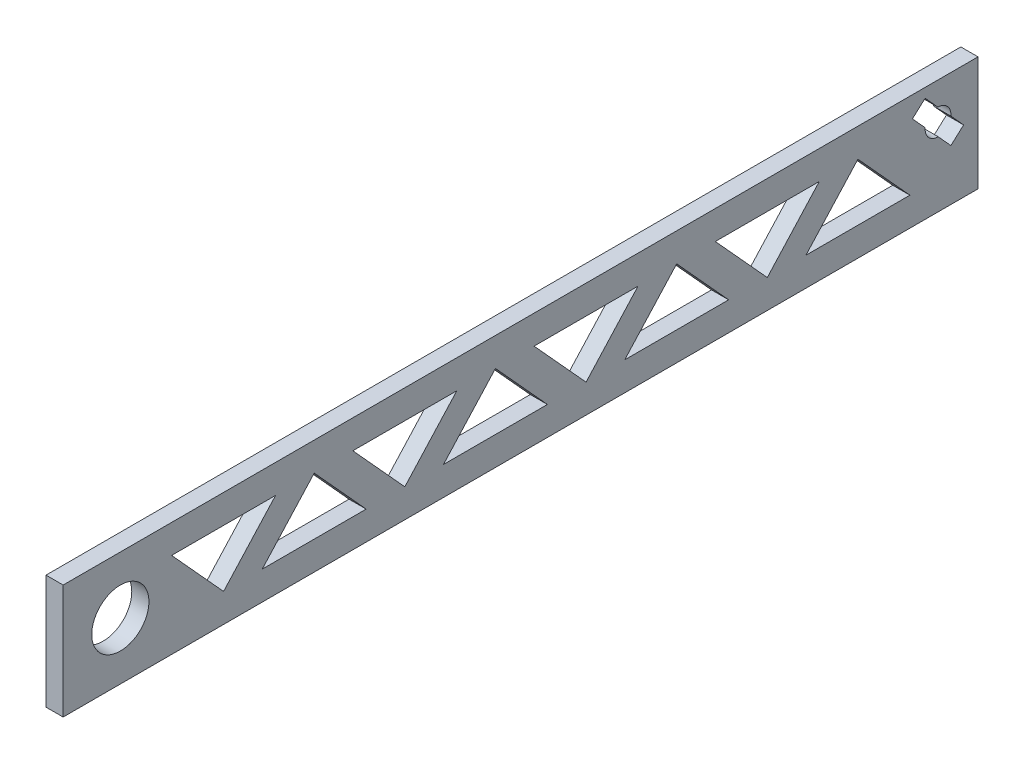
from build123d import *

# Parameters (mm, degrees)
SKETCH1_W           = 320
SKETCH1_H           = 40
SKETCH1_R           = 10
BOSS_EXTRUDE1_DEPTH = 6
CUT_EXTRUDE2_DEPTH  = 10
CUT_EXTRUDE3_DEPTH  = 7


with BuildPart() as part:
    # Sketch1 → Boss-Extrude1 (new body)
    with BuildSketch(Plane(origin=(0, 0, 0), x_dir=(0, 0, -1), z_dir=(1, 0, 0))):
        Rectangle(SKETCH1_W, SKETCH1_H)
        with Locations((-140, 0)):
            Circle(SKETCH1_R, mode=Mode.SUBTRACT)
    extrude(amount=BOSS_EXTRUDE1_DEPTH)

    # Sketch2 → Cut-Extrude2 (cut)
    with BuildSketch(Plane.ZY):
        Polygon((54.001630689, -10), (72.183448871, 10), (90.365267053, -10), align=None)
        Polygon((22.305204555, 10), (58.668840919, 10), (40.487022737, -10), align=None)
        Polygon((-9.391221579, -10), (8.790596603, 10), (26.972414785, -10), align=None)
        Polygon((-4.724011349, 10), (-22.905829531, -10), (-41.087647713, 10), align=None)
        Polygon((-36.420437483, -10), (-72.784073847, -10), (-54.602255665, 10), align=None)
        Polygon((-68.116863617, 10), (-86.298681799, -10), (-104.48049998, 10), align=None)
        Polygon((-99.813289751, -10), (-136.176926114, -10), (-117.995107933, 10), align=None)
        Polygon((85.698056823, 10), (122.061693187, 10), (103.879875005, -10), align=None)
    extrude(amount=-CUT_EXTRUDE2_DEPTH, mode=Mode.SUBTRACT)

    # Sketch3 → Cut-Extrude3 (cut, through all)
    with BuildSketch(Plane.ZY):
        with BuildLine():
            Line((-146.04862835, 2.783997553), (-150.521776952, -2.136465909))
            Line((-150.521776952, -2.136465909), (-154.961417393, 1.899570855))
            Line((-154.961417393, 1.899570855), (-150.488268791, 6.820034317))
            ThreePointArc((-150.488268791, 6.820034317), (-149.34196576, 10.310877963), (-145.975842509, 11.783703228))
            Line((-145.975842509, 11.783703228), (-141.502693907, 16.70416669))
            Line((-141.502693907, 16.70416669), (-137.063053466, 12.668129926))
            Line((-137.063053466, 12.668129926), (-141.536202068, 7.747666464))
            ThreePointArc((-141.536202068, 7.747666464), (-142.682505099, 4.256822817), (-146.04862835, 2.783997553))
        make_face()
    extrude(amount=-CUT_EXTRUDE3_DEPTH, mode=Mode.SUBTRACT)


solid = part.part
